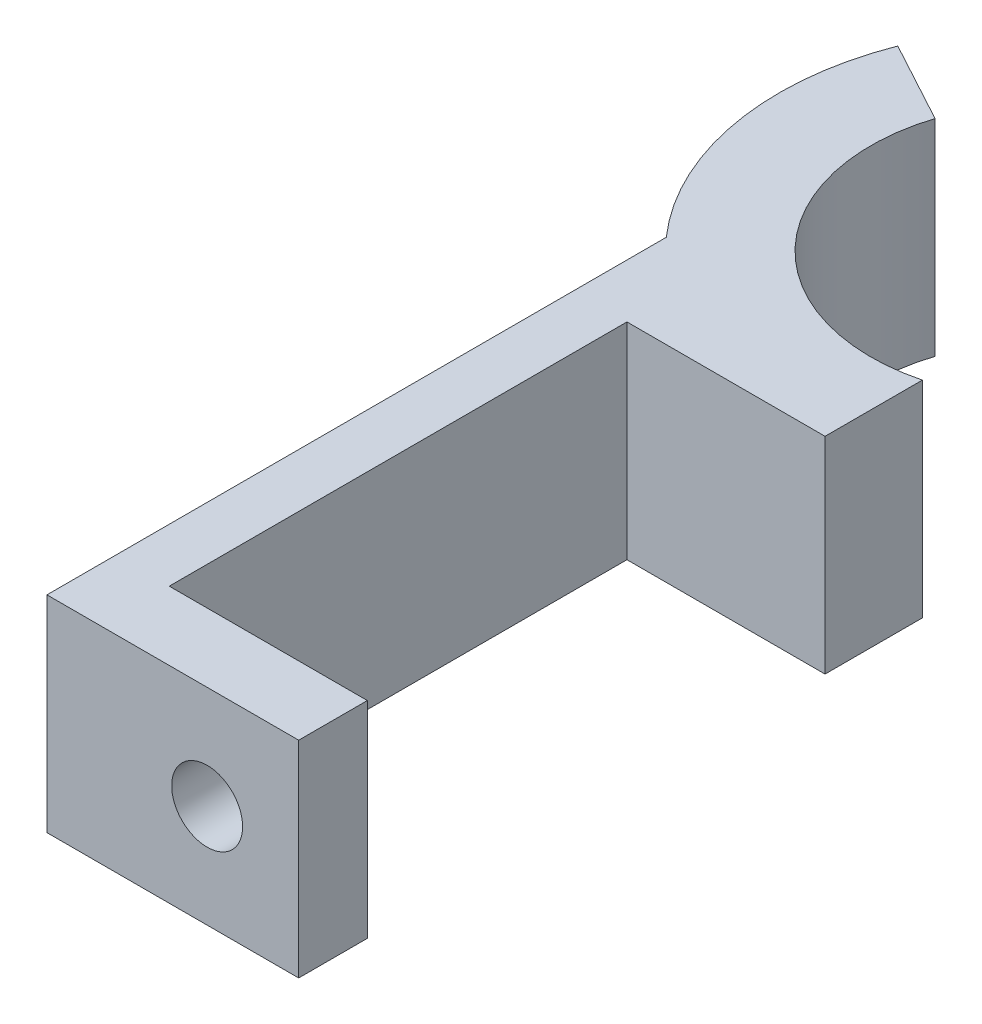
from build123d import *

# Parameters (mm, degrees)
BOSS_EXTRUDE1_DEPTH = 9
SKETCH2_R           = 1.55
CUT_EXTRUDE1_DEPTH  = 10


with BuildPart() as part:
    # Sketch1 → Boss-Extrude1 (new body)
    with BuildSketch(Plane(origin=(0, 0, 0), x_dir=(1, 0, 0), z_dir=(0, 1, 0))):
        with BuildLine():
            Line((5.5, 14.254033308), (5.5, 10))
            Line((5.5, 10), (-3.155943876, 10))
            Line((-3.155943876, 10), (-3.155943876, -10))
            Line((-3.155943876, -10), (5.5, -10))
            Line((5.5, -10), (5.5, -13))
            Line((5.5, -13), (-5.5, -13))
            Line((-5.5, -13), (-5.5, 14.062746067))
            ThreePointArc((-5.5, 14.062746067), (-8.315661291, 19.904731936), (-7.680431732, 26.358663359))
            Line((-7.680431732, 26.358663359), (-4.122387432, 24.428828902))
            ThreePointArc((-4.122387432, 24.428828902), (-2.312437222, 16.503130569), (5.5, 14.254033308))
        make_face()
    extrude(amount=BOSS_EXTRUDE1_DEPTH)

    # Sketch2 → Cut-Extrude1 (cut)
    with BuildSketch(Plane.XY.offset(13)):
        with Locations((1.5, 4.5)):
            Circle(SKETCH2_R)
    extrude(amount=-CUT_EXTRUDE1_DEPTH, mode=Mode.SUBTRACT)


solid = part.part
